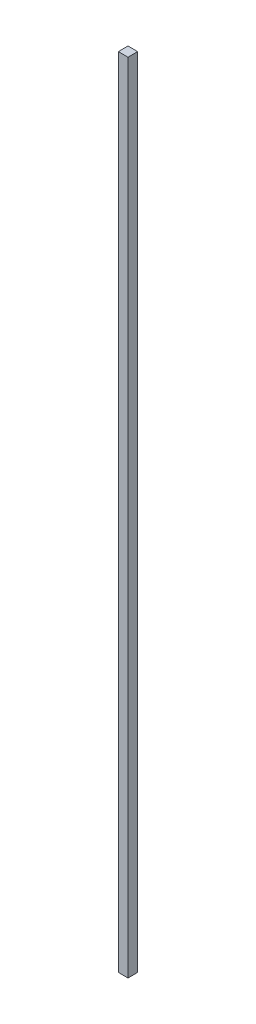
from build123d import *

# Parameters (mm, degrees)
SKETCH1_W           = 30
SKETCH1_H           = 2470
BOSS_EXTRUDE1_DEPTH = 15
SKETCH2_R           = 2.5
BOSS_EXTRUDE2_DEPTH = 10


with BuildPart() as part:
    # Sketch1 → Boss-Extrude1 (new body, symmetric)
    with BuildSketch(Plane(origin=(0, 0, 0), x_dir=(0, 0, -1), z_dir=(1, 0, 0))):
        with Locations((15, 1235)):
            Rectangle(SKETCH1_W, SKETCH1_H)
    extrude(amount=BOSS_EXTRUDE1_DEPTH, both=True)

    # Sketch2 → Boss-Extrude2 (add)
    with BuildSketch(Plane.XZ):
        with Locations((0, -15)):
            Circle(SKETCH2_R)
    extrude(amount=BOSS_EXTRUDE2_DEPTH)


solid = part.part
